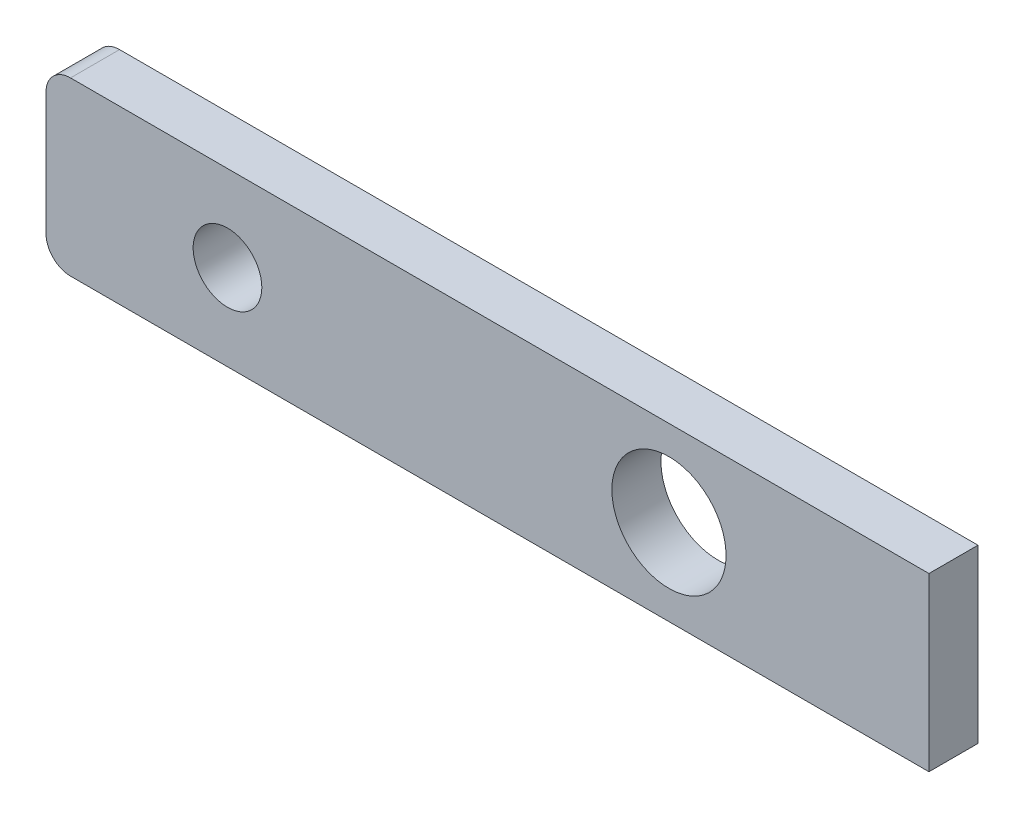
from build123d import *

# Parameters (mm, degrees)
SKETCH2_W           = 18
SKETCH2_H           = 3.5
BOSS_EXTRUDE1_DEPTH = 1
SKETCH3_R           = 0.7
CUT_EXTRUDE1_DEPTH  = 2
FILLET1_R           = 0.5
SKETCH4_OUTSIDE_W   = 23.672
SKETCH4_OUTSIDE_H   = 9.172
SKETCH4_OUTSIDE_R   = 1.164013777
CUT_EXTRUDE3_DEPTH  = 2


with BuildPart() as part:
    # Sketch2 → Boss-Extrude1 (new body)
    with BuildSketch(Plane.XY):
        Rectangle(SKETCH2_W, SKETCH2_H)
    extrude(amount=BOSS_EXTRUDE1_DEPTH)

    # Sketch3 → Cut-Extrude1 (cut, through all)
    with BuildSketch(Plane.XY.offset(1)):
        with Locations((-5.3, 0)):
            Circle(SKETCH3_R)
    extrude(amount=-CUT_EXTRUDE1_DEPTH, mode=Mode.SUBTRACT)

    # Fillet1
    fillet1_edges = [part.edges().sort_by_distance(p)[0] for p in [
        (-9, -1.75, 0.5),
        (-9, 1.75, 0.5),
    ]]
    fillet(fillet1_edges, radius=FILLET1_R)

    # Sketch4 outside → Cut-Extrude3 (cut, through all)
    with BuildSketch(Plane(origin=(0, 0, 0), x_dir=(-1, 0, 0), z_dir=(0, 0, -1))):
        Rectangle(SKETCH4_OUTSIDE_W, SKETCH4_OUTSIDE_H)
        with BuildLine():
            Line((-9, -1.75), (8.5, -1.75))
            ThreePointArc((8.5, -1.75), (8.853553391, -1.603553391), (9, -1.25))
            Line((9, -1.25), (9, 1.25))
            ThreePointArc((9, 1.25), (8.853553391, 1.603553391), (8.5, 1.75))
            Line((8.5, 1.75), (-9, 1.75))
            Line((-9, 1.75), (-9, -1.75))
        make_face(mode=Mode.SUBTRACT)
        with Locations((-3.7, 0)):
            Circle(SKETCH4_OUTSIDE_R)
    extrude(amount=-CUT_EXTRUDE3_DEPTH, mode=Mode.SUBTRACT)


solid = part.part
